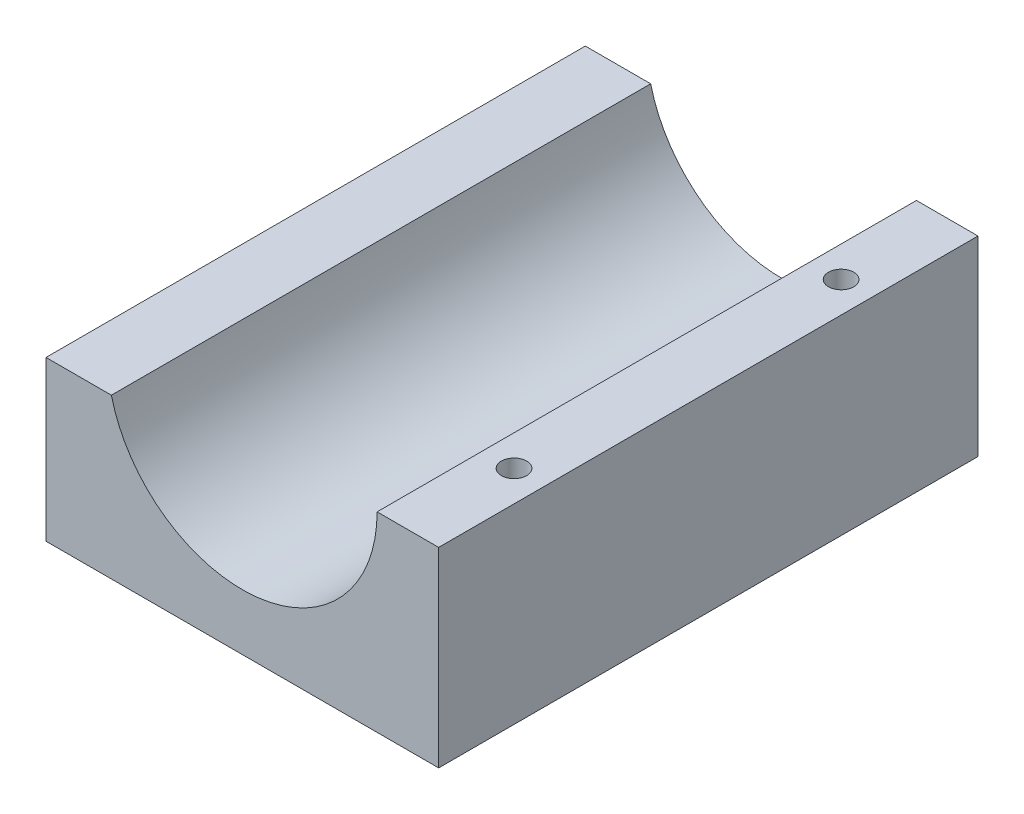
from build123d import *

# Parameters (mm, degrees)
SKETCH2_W                 = 18.5
SKETCH2_H                 = 25.41
BOSS_EXTRUDE1_DEPTH       = 9
CUT_EXTRUDE1_DEPTH        = 25.41
F_0_80_TAPPED_HOLE1_D     = 1.19126
F_0_80_TAPPED_HOLE1_DEPTH = 3.642109389
F_0_80_TAPPED_HOLE1_TIP   = 0.357890611
CUT_EXTRUDE3_DEPTH        = 33.694312961
CUT_EXTRUDE3_DEPTH_BACK   = 25.41
F_2_56_TAPPED_HOLE3_D     = 1.778
F_2_56_TAPPED_HOLE3_DEPTH = 3.46583491
F_2_56_TAPPED_HOLE3_TIP   = 0.53416509


with BuildPart() as part:
    # Sketch2 → Boss-Extrude1 (new body)
    with BuildSketch(Plane(origin=(0, 0, 0), x_dir=(1, 0, 0), z_dir=(0, 1, 0))):
        with Locations((9.25, 12.705)):
            Rectangle(SKETCH2_W, SKETCH2_H)
    extrude(amount=BOSS_EXTRUDE1_DEPTH)

    # Sketch6 → Cut-Extrude1 (cut)
    with BuildSketch(Plane.XY):
        with BuildLine():
            Line((2.9, 9), (15.6, 9))
            ThreePointArc((15.6, 9), (9.25, 2.65), (2.9, 9))
        make_face()
    extrude(amount=-CUT_EXTRUDE1_DEPTH, mode=Mode.SUBTRACT)

    # #0-80 Tapped Hole1
    with Locations(Plane(origin=(0, 9, 0), x_dir=(1, 0, 0), z_dir=(0, 1, 0))):
        with Locations((17.05, 20.41), (17.05, 5)):
            Hole(F_0_80_TAPPED_HOLE1_D / 2, depth=F_0_80_TAPPED_HOLE1_DEPTH)
            with Locations((0, 0, -(F_0_80_TAPPED_HOLE1_DEPTH + F_0_80_TAPPED_HOLE1_TIP / 2))):  # 118° drill point
                Cone(0, F_0_80_TAPPED_HOLE1_D / 2, F_0_80_TAPPED_HOLE1_TIP, mode=Mode.SUBTRACT)

    # Sketch14 → Cut-Extrude3 (cut, two sides)
    with BuildSketch(Plane(origin=(0, 0, -25.41), x_dir=(-1, 0, 0), z_dir=(0, 0, -1))) as cut_extrude3_sk:
        Polygon((0, 60.146081223), (0, 9), (0, 7.5), (-3.246658661, 7.5), (-2.9, 9), (8.616604878, 58.832614185), (24.031387378, 159.956651774), (15.4147825, 161.270118812), align=None)
    extrude(amount=CUT_EXTRUDE3_DEPTH, mode=Mode.SUBTRACT)
    extrude(cut_extrude3_sk.sketch, amount=-CUT_EXTRUDE3_DEPTH_BACK, mode=Mode.SUBTRACT)


with BuildPart() as cut_extrude3_kept_piece:
    # of the separate pieces the step leaves, the one the design keeps (cut_extrude3_pieces_kept)
    add(part.part.solids().sort_by_distance((0, 0, 0))[0])

    # #2-56 Tapped Hole3
    with Locations(Plane(origin=(0, 0, 0), x_dir=(-1, 0, 0), z_dir=(0, -1, 0))):
        with Locations((-17, 12.705), (-1.5, 12.705)):
            Hole(F_2_56_TAPPED_HOLE3_D / 2, depth=F_2_56_TAPPED_HOLE3_DEPTH)
            with Locations((0, 0, -(F_2_56_TAPPED_HOLE3_DEPTH + F_2_56_TAPPED_HOLE3_TIP / 2))):  # 118° drill point
                Cone(0, F_2_56_TAPPED_HOLE3_D / 2, F_2_56_TAPPED_HOLE3_TIP, mode=Mode.SUBTRACT)


solid = cut_extrude3_kept_piece.part
